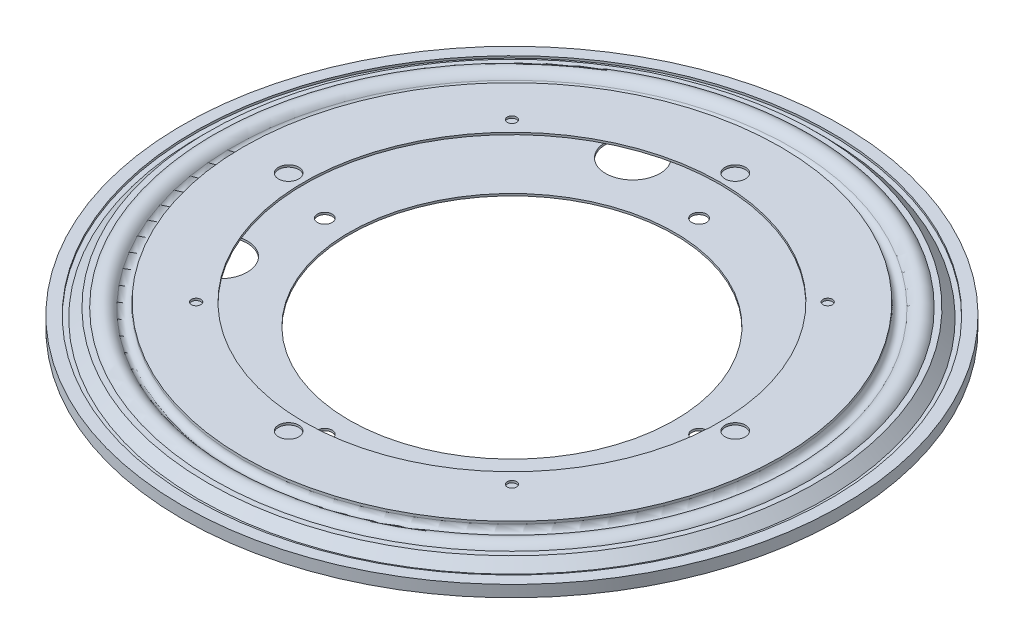
from build123d import *

# Parameters (mm, degrees)
CIRPATTERN1_COUNT  = 9
SKETCH3_R          = 9.525
CUT_EXTRUDE1_DEPTH = 1.7366001
SKETCH4_W          = 3.571875
SKETCH4_H          = 0.7376
CIRPATTERN2_COUNT  = 4
CIRPATTERN3_COUNT  = 4
SKETCH8_W          = 1.651
SKETCH8_H          = 0.7376
CIRPATTERN4_COUNT  = 4


with BuildPart() as part:
    # Sketch1 → Revolve-Thin1 (revolve)
    with BuildSketch(Plane.XY):
        with BuildLine():
            Line((111.6965, 0), (115.7605, 0))
            Line((115.7605, 0), (115.7605, -4.064))
            Line((115.7605, -4.064), (108.835901517, -4.064))
            Line((108.835901517, -4.064), (108.835901517, -3.175))
            ThreePointArc((108.835901517, -3.175), (107.35355961, -1.218753599), (105.069267678, -2.116666667))
            ThreePointArc((105.069267678, -2.116666667), (101.6, -4.064), (98.130732322, -2.116666667))
            ThreePointArc((98.130732322, -2.116666667), (95.84644039, -1.218753599), (94.364098483, -3.175))
            Line((94.364098483, -3.175), (94.364098483, -4.064))
            Line((94.364098483, -4.064), (57.15, -4.064))
            Line((57.15, -4.064), (57.15, -3.3274))
            Line((57.15, -3.3274), (93.627498483, -3.3274))
            Line((93.627498483, -3.3274), (93.627498483, -3.175))
            ThreePointArc((93.627498483, -3.175), (95.647189331, -0.509614279), (98.759537089, -1.733020833))
            ThreePointArc((98.759537089, -1.733020833), (101.6, -3.3274), (104.440462911, -1.733020833))
            ThreePointArc((104.440462911, -1.733020833), (107.552810669, -0.509614279), (109.572501517, -3.175))
            Line((109.572501517, -3.175), (109.572501517, -3.3274))
            Line((109.572501517, -3.3274), (115.0239, -3.3274))
            Line((115.0239, -3.3274), (115.0239, -0.7366))
            Line((115.0239, -0.7366), (111.6965, -0.7366))
            Line((111.6965, -0.7366), (111.6965, 0))
        make_face()
    revolve(axis=Axis((0, 21.71272626, 0), (0, -1, 0)))

    # Sketch3 → Cut-Extrude1 (cut, through all)
    with BuildSketch(Plane(origin=(0, -3.3274, 0), x_dir=(-1, 0, 0), z_dir=(0, 1, 0))):
        with Locations((30.015851554, -72.464675908)):
            Circle(SKETCH3_R)
    cut_extrude1 = extrude(amount=-CUT_EXTRUDE1_DEPTH, mode=Mode.SUBTRACT)

    # Sketch6 → 13_64 _0.203130_ Diameter Hole1 (revolve, cut)
    with BuildSketch(Plane(origin=(0, -3.3274, -65.7352), x_dir=(0, 0, 1), z_dir=(1, 0, 0))):
        Polygon((0, 0), (0, 9.678070783), (2.579751, 8.128), (2.579751, 0), align=None)
    f_13_64_0_203130_diameter_hole1 = revolve(axis=Axis((0, 3.0226, -65.7352), (0, -1, 0)), mode=Mode.SUBTRACT)

    # CirPattern3: Cut-Extrude1, 13_64 _0.203130_ Diameter Hole1 ×4 about axis
    cirpattern3_axis = Axis((0, 0, 0), (0, 1, 0))
    for i in range(1, CIRPATTERN3_COUNT):
        add(cut_extrude1.rotate(cirpattern3_axis, i * 360 / CIRPATTERN3_COUNT), mode=Mode.SUBTRACT)
        add(f_13_64_0_203130_diameter_hole1.rotate(cirpattern3_axis, i * 360 / CIRPATTERN3_COUNT), mode=Mode.SUBTRACT)


with BuildPart() as body_2:
    # Sketch1_7 → Revolve-Thin2 (revolve)
    with BuildSketch(Plane.XY):
        with BuildLine():
            Line((113.7285, -0.889), (110.085660312, -0.889))
            Line((110.085660312, -0.889), (106.803901517, 2.392758795))
            Line((106.803901517, 2.392758795), (104.884935517, 2.392758795))
            ThreePointArc((104.884935517, 2.392758795), (101.43401415, 4.060608907), (98.130732322, 2.116666667))
            ThreePointArc((98.130732322, 2.116666667), (95.84644039, 1.218753599), (94.364098483, 3.175))
            Line((94.364098483, 3.175), (94.364098483, 4.064))
            Line((94.364098483, 4.064), (73.025, 4.064))
            Line((73.025, 4.064), (73.025, 3.3274))
            Line((73.025, 3.3274), (93.627498483, 3.3274))
            Line((93.627498483, 3.3274), (93.627498483, 3.175))
            ThreePointArc((93.627498483, 3.175), (95.647189331, 0.509614279), (98.759537089, 1.733020833))
            ThreePointArc((98.759537089, 1.733020833), (101.644657546, 3.327100309), (104.485953708, 1.656158795))
            Line((104.485953708, 1.656158795), (106.498791807, 1.656158795))
            Line((106.498791807, 1.656158795), (109.780550602, -1.6256))
            Line((109.780550602, -1.6256), (113.7285, -1.6256))
            Line((113.7285, -1.6256), (113.7285, -0.889))
        make_face()
    revolve(axis=Axis((0, 21.71272626, 0), (0, -1, 0)))

    # Sketch4 → 9_32 _0.281250_ Diameter Hole1 (revolve, cut)
    with BuildSketch(Plane(origin=(0, 4.064, -78.4352), x_dir=(0, 0, 1), z_dir=(1, 0, 0))):
        with Locations((1.7859375, 0.3688)):
            Rectangle(SKETCH4_W, SKETCH4_H)
    f_9_32_0_281250_diameter_hole1 = revolve(axis=Axis((0, 10.414, -78.4352), (0, -1, 0)), mode=Mode.SUBTRACT)

    # CirPattern2: 9_32 _0.281250_ Diameter Hole1 ×4 about axis
    cirpattern2_axis = Axis((0, 0, 0), (0, 1, 0))
    for i in range(1, CIRPATTERN2_COUNT):
        add(f_9_32_0_281250_diameter_hole1.rotate(cirpattern2_axis, i * 360 / CIRPATTERN2_COUNT), mode=Mode.SUBTRACT)

    # Sketch8 → 97 _0.005900_ Diameter Hole1 (revolve, cut)
    with BuildSketch(Plane(origin=(-55.462061804, 4.064, 55.462061804), x_dir=(0, 0, 1), z_dir=(1, 0, 0))):
        with Locations((0.8255, 0.3688)):
            Rectangle(SKETCH8_W, SKETCH8_H)
    f_97_0_005900_diameter_hole1 = revolve(axis=Axis((-55.462061804, 10.414, 55.462061804), (0, -1, 0)), mode=Mode.SUBTRACT)

    # CirPattern4: 97 _0.005900_ Diameter Hole1 ×4 about axis
    cirpattern4_axis = Axis((0, 0, 0), (0, 1, 0))
    for i in range(1, CIRPATTERN4_COUNT):
        add(f_97_0_005900_diameter_hole1.rotate(cirpattern4_axis, i * 360 / CIRPATTERN4_COUNT), mode=Mode.SUBTRACT)


with BuildPart() as body_3:
    # Sketch2 → Revolve1 (revolve)
    with BuildSketch(Plane.XY):
        with BuildLine():
            Line((101.6, 3.2766), (101.6, -3.2766))
            ThreePointArc((101.6, -3.2766), (104.8766, 0), (101.6, 3.2766))
        make_face()
    revolve(axis=Axis((101.6, 5.355428419, 0), (0, -1, 0)))


with BuildPart() as cirpattern1_1:
    # CirPattern1: pattern copy
    add(body_3.part.rotate(Axis((0, 0, 0), (0, 1, 0)), 1 * 360 / CIRPATTERN1_COUNT))


with BuildPart() as cirpattern1_2:
    # CirPattern1: pattern copy
    add(body_3.part.rotate(Axis((0, 0, 0), (0, 1, 0)), 2 * 360 / CIRPATTERN1_COUNT))


with BuildPart() as cirpattern1_3:
    # CirPattern1: pattern copy
    add(body_3.part.rotate(Axis((0, 0, 0), (0, 1, 0)), 3 * 360 / CIRPATTERN1_COUNT))


with BuildPart() as cirpattern1_4:
    # CirPattern1: pattern copy
    add(body_3.part.rotate(Axis((0, 0, 0), (0, 1, 0)), 4 * 360 / CIRPATTERN1_COUNT))


with BuildPart() as cirpattern1_5:
    # CirPattern1: pattern copy
    add(body_3.part.rotate(Axis((0, 0, 0), (0, 1, 0)), 5 * 360 / CIRPATTERN1_COUNT))


with BuildPart() as cirpattern1_6:
    # CirPattern1: pattern copy
    add(body_3.part.rotate(Axis((0, 0, 0), (0, 1, 0)), 6 * 360 / CIRPATTERN1_COUNT))


with BuildPart() as cirpattern1_7:
    # CirPattern1: pattern copy
    add(body_3.part.rotate(Axis((0, 0, 0), (0, 1, 0)), 7 * 360 / CIRPATTERN1_COUNT))


with BuildPart() as cirpattern1_8:
    # CirPattern1: pattern copy
    add(body_3.part.rotate(Axis((0, 0, 0), (0, 1, 0)), 8 * 360 / CIRPATTERN1_COUNT))


solid = Compound([part.part, body_2.part, body_3.part, cirpattern1_1.part, cirpattern1_2.part, cirpattern1_3.part, cirpattern1_4.part, cirpattern1_5.part, cirpattern1_6.part, cirpattern1_7.part, cirpattern1_8.part])
